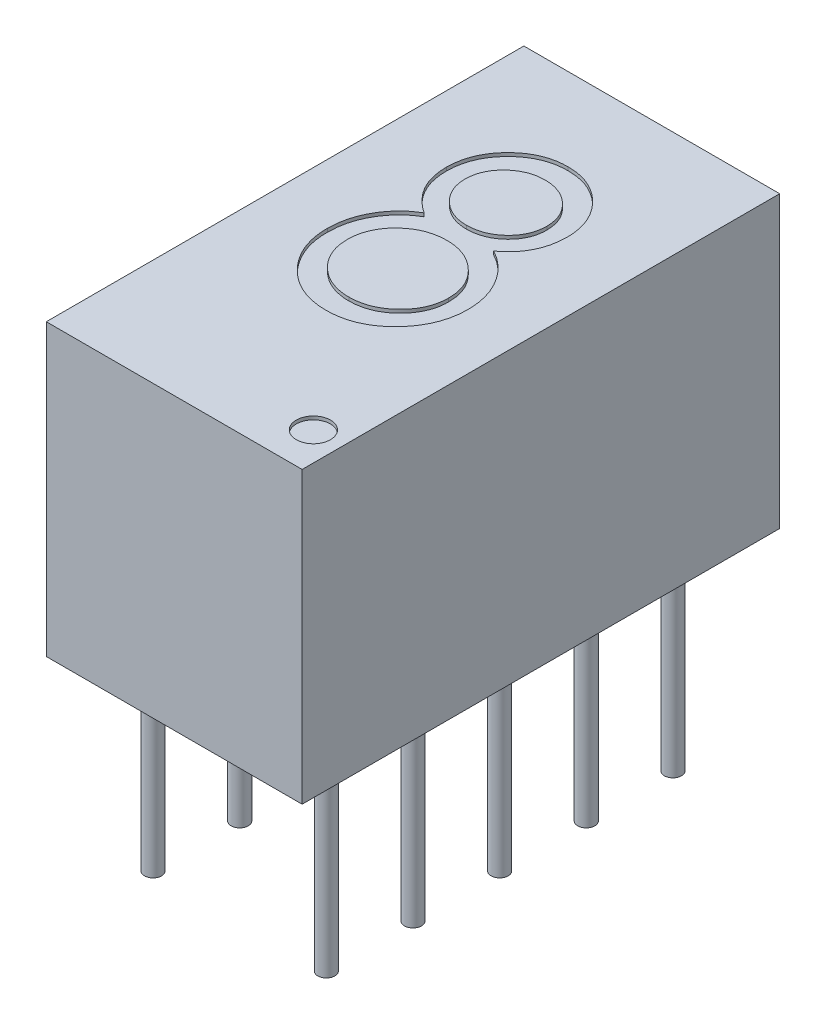
from build123d import *

# Parameters (mm, degrees)
SKETCH_1_W          = 7.5
SKETCH_1_H          = 14
EXTRUDE_1_DEPTH     = 8.5
SKETCH_3_R          = 0.5
CUT_EXTRUDE_1_DEPTH = 0.1
SKETCH_5_R          = 0.25
EXTRUDE_2_DEPTH     = 5.8


with BuildPart() as part:
    # Эскиз1 → Бобышка-Вытянуть1 (new body)
    with BuildSketch(Plane(origin=(0, 0, 0), x_dir=(1, 0, 0), z_dir=(0, 1, 0))):
        Rectangle(SKETCH_1_W, SKETCH_1_H)
    extrude(amount=EXTRUDE_1_DEPTH)

    # Эскиз3 → Вырез-Вытянуть1 (cut)
    with BuildSketch(Plane(origin=(0, 8.5, 0), x_dir=(1, 0, 0), z_dir=(0, 1, 0))):
        with Locations((2.910485727, -5.830946725)):
            Circle(SKETCH_3_R)
        with BuildLine():
            add(Edge.make_bspline(
                [(2.121155078, -0.50483922), (2.119610921, -0.575353546), (2.116575096, -0.713985319), (2.087040205, -0.918279661), (2.038961712, -1.114797376), (1.973166577, -1.304892703), (1.886688616, -1.487323172), (1.78197659, -1.662562127), (1.657407987, -1.830055464), (1.517294235, -1.98880673), (1.361960172, -2.13209451), (1.200545821, -2.261845857), (1.027958933, -2.367621456), (0.84976884, -2.457639593), (0.662148452, -2.524316616), (0.468390235, -2.574879029), (0.266226934, -2.603112848), (0.129148301, -2.607543917), (0.05965128, -2.609790409)],
                knots=[0, 0, 0, 0, 0.000211435, 0.000415684, 0.000617717, 0.000817667, 0.001018055, 0.00122232, 0.001429075, 0.001643446, 0.00185651, 0.002062417, 0.002263626, 0.00246262, 0.00266025, 0.002859739, 0.003062504, 0.003271016, 0.003271016, 0.003271016, 0.003271016], degree=3))
            add(Edge.make_bspline(
                [(0.05965128, -2.609790409), (-0.010888995, -2.608419751), (-0.149643242, -2.605723636), (-0.353155485, -2.573755937), (-0.549123033, -2.526529422), (-0.737102681, -2.458914193), (-0.91663966, -2.371071457), (-1.088089808, -2.264481517), (-1.250652143, -2.137279423), (-1.403333726, -1.993108779), (-1.54323465, -1.836036279), (-1.665173304, -1.668662471), (-1.769604, -1.493894771), (-1.854844828, -1.311174219), (-1.921926234, -1.120612112), (-1.967350345, -0.922026502), (-1.997320876, -0.715997722), (-2.000328331, -0.575860925), (-2.001852517, -0.50483922)],
                knots=[0, 0, 0, 0, 0.000211435, 0.000415898, 0.000616476, 0.000815515, 0.001013848, 0.001215057, 0.00142004, 0.001632011, 0.001844268, 0.002050136, 0.002252347, 0.002454091, 0.002654041, 0.002857182, 0.003064398, 0.00327733, 0.00327733, 0.00327733, 0.00327733], degree=3))
            add(Edge.make_bspline(
                [(-2.001852517, -0.50483922), (-1.998385166, -0.411697298), (-1.991524819, -0.227410851), (-1.937031265, 0.043125235), (-1.849797453, 0.303070227), (-1.728226024, 0.549500305), (-1.5780525, 0.777866462), (-1.401784211, 0.981324501), (-1.202163202, 1.158762714), (-1.052445588, 1.253030314), (-0.977093362, 1.300474789)],
                knots=[0, 0, 0, 0, 0.000279242, 0.000552496, 0.00082444, 0.001099821, 0.001374484, 0.001642127, 0.001905399, 0.002172165, 0.002172165, 0.002172165, 0.002172165], degree=3))
            add(Edge.make_bspline(
                [(-0.977093362, 1.300474789), (-1.043186061, 1.347447939), (-1.172133067, 1.439092663), (-1.341577528, 1.598037796), (-1.487767424, 1.766027966), (-1.605421669, 1.947906942), (-1.698278534, 2.140942889), (-1.762013938, 2.346493715), (-1.802508183, 2.56285791), (-1.807525807, 2.71108272), (-1.810084722, 2.786675201)],
                knots=[0, 0, 0, 0, 0.000243006, 0.000474106, 0.000695108, 0.000909532, 0.001121962, 0.001335658, 0.001553411, 0.001780038, 0.001780038, 0.001780038, 0.001780038], degree=3))
            add(Edge.make_bspline(
                [(-1.810084722, 2.786675201), (-1.808972335, 2.846711132), (-1.806774097, 2.965350854), (-1.779413863, 3.139691302), (-1.740089645, 3.308165859), (-1.681905998, 3.47001905), (-1.608962983, 3.626021501), (-1.518236321, 3.77457472), (-1.412130887, 3.917202284), (-1.290733708, 4.051067508), (-1.158608385, 4.17524507), (-1.017343615, 4.283306119), (-0.869940426, 4.375317638), (-0.71599843, 4.451100091), (-0.555144437, 4.509354088), (-0.388150174, 4.551898183), (-0.214204315, 4.57574584), (-0.096229339, 4.579561458), (-0.036232617, 4.581501909)],
                knots=[0, 0, 0, 0, 0.000179938, 0.000355584, 0.000528188, 0.000698303, 0.000870542, 0.001043976, 0.001219565, 0.001403085, 0.001585409, 0.001762803, 0.001935744, 0.002105932, 0.002276554, 0.002448062, 0.002622013, 0.00280202, 0.00280202, 0.00280202, 0.00280202], degree=3))
            add(Edge.make_bspline(
                [(-0.036232617, 4.581501909), (0.023764104, 4.579561458), (0.141739081, 4.57574584), (0.31568494, 4.551898183), (0.482679202, 4.509354088), (0.643533196, 4.451100091), (0.797475192, 4.375317638), (0.944878381, 4.283306119), (1.086143151, 4.17524507), (1.218268473, 4.051067508), (1.339665653, 3.917202284), (1.445771086, 3.77457472), (1.536497749, 3.626021501), (1.609440763, 3.47001905), (1.66762441, 3.308165859), (1.706948628, 3.139691302), (1.734308862, 2.965350854), (1.736507101, 2.846711132), (1.737619488, 2.786675201)],
                knots=[0, 0, 0, 0, 0.000180007, 0.000353958, 0.000525466, 0.000696088, 0.000866276, 0.001039217, 0.001216611, 0.001398935, 0.001582455, 0.001758044, 0.001931478, 0.002103717, 0.002273832, 0.002446436, 0.002622082, 0.00280202, 0.00280202, 0.00280202, 0.00280202], degree=3))
            add(Edge.make_bspline(
                [(1.737619488, 2.786675201), (1.735184421, 2.712644696), (1.730437273, 2.568322681), (1.697189905, 2.35741071), (1.640449844, 2.159073672), (1.559865791, 1.972574079), (1.457523684, 1.797749946), (1.331889434, 1.634553362), (1.182929281, 1.484074534), (1.069965336, 1.396145165), (1.012497512, 1.351413109)],
                knots=[0, 0, 0, 0, 0.000222055, 0.000432895, 0.000638687, 0.000839344, 0.001040793, 0.00124486, 0.001455678, 0.001673987, 0.001673987, 0.001673987, 0.001673987], degree=3))
            add(Edge.make_bspline(
                [(1.012497512, 1.351413109), (1.094458905, 1.30429308), (1.256819208, 1.210951299), (1.472423159, 1.030313715), (1.663050375, 0.823489416), (1.825135584, 0.590307377), (1.957738762, 0.337664387), (2.053020331, 0.068458504), (2.109517853, -0.214336998), (2.117243932, -0.407204555), (2.121155078, -0.50483922)],
                knots=[0, 0, 0, 0, 0.000283161, 0.000560924, 0.000839784, 0.0011249, 0.001410363, 0.00169325, 0.001978842, 0.002271637, 0.002271637, 0.002271637, 0.002271637], degree=3))
        make_face()
        with BuildLine():
            add(Edge.make_bspline(
                [(1.162316102, 2.759707855), (1.161075378, 2.798720743), (1.15861475, 2.876091878), (1.141765656, 2.989486371), (1.115264605, 3.098804143), (1.075065423, 3.202673942), (1.026675542, 3.303581185), (0.963410683, 3.398216702), (0.89238902, 3.489973671), (0.809199314, 3.574295156), (0.721254942, 3.654189791), (0.624225127, 3.720604954), (0.525307508, 3.780015185), (0.421256004, 3.828950352), (0.31107067, 3.863741424), (0.197666531, 3.891693293), (0.078997247, 3.906225352), (-0.001242231, 3.908932118), (-0.042225361, 3.910314626)],
                knots=[0, 0, 0, 0, 0.000117012, 0.000232061, 0.00034325, 0.00045372, 0.000565614, 0.000678227, 0.000794518, 0.000913187, 0.001033126, 0.001150339, 0.001265192, 0.001379143, 0.00149427, 0.001611282, 0.001729097, 0.001852094, 0.001852094, 0.001852094, 0.001852094], degree=3))
            add(Edge.make_bspline(
                [(-0.042225361, 3.910314626), (-0.082209817, 3.908913676), (-0.160954084, 3.906154686), (-0.277148491, 3.891770235), (-0.388787542, 3.863901364), (-0.49651117, 3.827154112), (-0.599487682, 3.778059387), (-0.699216345, 3.719527302), (-0.794156904, 3.649253124), (-0.883884385, 3.570043388), (-0.965685909, 3.483868338), (-1.037754392, 3.392809573), (-1.098416383, 3.297357827), (-1.148016212, 3.197942274), (-1.187671947, 3.094265098), (-1.213902123, 2.985950239), (-1.231208909, 2.874121395), (-1.233578617, 2.798227166), (-1.234781337, 2.759707855)],
                knots=[0, 0, 0, 0, 0.000120005, 0.000236334, 0.000350432, 0.000464619, 0.000577212, 0.000692066, 0.000811028, 0.000930967, 0.001050719, 0.001167009, 0.001278812, 0.001389364, 0.001499834, 0.001611023, 0.001723107, 0.001838623, 0.001838623, 0.001838623, 0.001838623], degree=3))
            add(Edge.make_bspline(
                [(-1.234781337, 2.759707855), (-1.233578192, 2.721188809), (-1.231207647, 2.645295103), (-1.213906984, 2.533462436), (-1.187653911, 2.425161873), (-1.148083103, 2.321431669), (-1.097975151, 2.221836784), (-1.038257303, 2.12529264), (-0.965636158, 2.034066276), (-0.883830158, 1.94796263), (-0.794642747, 1.868490183), (-0.698717542, 1.800077719), (-0.59955118, 1.741268793), (-0.496494033, 1.69228522), (-0.388792152, 1.655507991), (-0.277147237, 1.627647204), (-0.160954412, 1.613260572), (-0.082209927, 1.610501881), (-0.042225361, 1.609101084)],
                knots=[0, 0, 0, 0, 0.000115516, 0.0002276, 0.000338789, 0.000449259, 0.000559811, 0.000672882, 0.000789172, 0.000908924, 0.001028863, 0.001146944, 0.001261798, 0.001374391, 0.001488578, 0.001602677, 0.001719006, 0.00183901, 0.00183901, 0.00183901, 0.00183901], degree=3))
            add(Edge.make_bspline(
                [(-0.042225361, 1.609101084), (-0.001242806, 1.610484513), (0.078995548, 1.613193083), (0.197672976, 1.62771208), (0.311046814, 1.655712546), (0.421343122, 1.690325638), (0.524757329, 1.739809218), (0.625269058, 1.796731093), (0.720073599, 1.865725278), (0.810428313, 1.943320751), (0.891188265, 2.029510208), (0.964495745, 2.119889496), (1.026137504, 2.215704432), (1.075158792, 2.31667649), (1.11523958, 2.420629063), (1.141772604, 2.529924481), (1.158612953, 2.643325088), (1.161074776, 2.720695388), (1.162316102, 2.759707855)],
                knots=[0, 0, 0, 0, 0.000122997, 0.000240812, 0.000357824, 0.000472951, 0.000586902, 0.000701, 0.000819082, 0.000938034, 0.001057786, 0.001172903, 0.001286775, 0.001398668, 0.001509139, 0.001620328, 0.001735376, 0.001852388, 0.001852388, 0.001852388, 0.001852388], degree=3))
        make_face(mode=Mode.SUBTRACT)
        with BuildLine():
            add(Edge.make_bspline(
                [(1.545851693, -0.500344662), (1.544153958, -0.451855548), (1.540797539, -0.355992638), (1.521912321, -0.214586624), (1.486385978, -0.078878813), (1.439649655, 0.052090021), (1.37423574, 0.175513927), (1.300428005, 0.296419548), (1.209485269, 0.410175017), (1.106669809, 0.516865469), (0.995617169, 0.61556725), (0.876490514, 0.700782673), (0.753627246, 0.774750266), (0.625577327, 0.835782464), (0.49086962, 0.88025421), (0.351479831, 0.91284097), (0.207198333, 0.935376603), (0.109177753, 0.937062151), (0.05965128, 0.937913801)],
                knots=[0, 0, 0, 0, 0.000145517, 0.000287687, 0.000426857, 0.000565736, 0.000703765, 0.000845103, 0.000990172, 0.001139578, 0.001289255, 0.001435203, 0.001578317, 0.001719059, 0.001859768, 0.002002945, 0.002148292, 0.002296734, 0.002296734, 0.002296734, 0.002296734], degree=3))
            add(Edge.make_bspline(
                [(0.05965128, 0.937913801), (0.00912817, 0.937072228), (-0.090381515, 0.935414676), (-0.236208949, 0.913049965), (-0.37648498, 0.880004823), (-0.512228317, 0.835790597), (-0.641453165, 0.775068656), (-0.764514464, 0.701225845), (-0.88238141, 0.615000101), (-0.993331096, 0.517357603), (-1.094824023, 0.410168268), (-1.183781181, 0.295848801), (-1.258672574, 0.176398459), (-1.319613031, 0.051221428), (-1.36732232, -0.078758138), (-1.40254451, -0.214619583), (-1.421511888, -0.355984096), (-1.424857077, -0.451852678), (-1.426549132, -0.500344662)],
                knots=[0, 0, 0, 0, 0.000151435, 0.000298265, 0.000441442, 0.000583572, 0.000725671, 0.000868785, 0.001013521, 0.001163197, 0.001311571, 0.001455716, 0.001597055, 0.001733743, 0.001872623, 0.002011793, 0.002153963, 0.00229948, 0.00229948, 0.00229948, 0.00229948], degree=3))
            add(Edge.make_bspline(
                [(-1.426549132, -0.500344662), (-1.424863171, -0.548839057), (-1.421530029, -0.644712406), (-1.402474508, -0.786042045), (-1.367695307, -0.921577873), (-1.318860571, -1.051086568), (-1.259165188, -1.176823553), (-1.183710808, -1.296504978), (-1.094844924, -1.410869775), (-0.993320444, -1.518032221), (-0.882402459, -1.61573548), (-0.764443776, -1.701752563), (-0.641890452, -1.776247054), (-0.511511058, -1.834173808), (-0.376862879, -1.881268219), (-0.236148072, -1.913571642), (-0.090397457, -1.936147903), (0.009122801, -1.937776337), (0.05965128, -1.938603126)],
                knots=[0, 0, 0, 0, 0.000145517, 0.000287687, 0.000426857, 0.000564331, 0.000702368, 0.000843706, 0.000987852, 0.001136225, 0.001285901, 0.001430637, 0.001573751, 0.001715225, 0.001857836, 0.002001013, 0.002147843, 0.002299278, 0.002299278, 0.002299278, 0.002299278], degree=3))
            add(Edge.make_bspline(
                [(0.05965128, -1.938603126), (0.109181661, -1.937762999), (0.207209976, -1.936100257), (0.351434673, -1.913397141), (0.491193008, -1.881395144), (0.625275202, -1.834568957), (0.753621302, -1.774002086), (0.876930115, -1.700068923), (0.995585152, -1.613120289), (1.10676909, -1.513096766), (1.20905995, -1.404961574), (1.30041366, -1.291133766), (1.374707371, -1.169940744), (1.438910667, -1.045956106), (1.486506033, -0.915895611), (1.521701785, -0.782082876), (1.5409119, -0.642725342), (1.544186525, -0.548340143), (1.545851693, -0.500344662)],
                knots=[0, 0, 0, 0, 0.000148441, 0.000293789, 0.000436965, 0.000578161, 0.000718903, 0.000862017, 0.001008847, 0.001159517, 0.001310008, 0.001455077, 0.001596416, 0.001735779, 0.001873253, 0.002010972, 0.002150175, 0.002294196, 0.002294196, 0.002294196, 0.002294196], degree=3))
        make_face(mode=Mode.SUBTRACT)
    extrude(amount=-CUT_EXTRUDE_1_DEPTH, mode=Mode.SUBTRACT)

    # Эскиз5 → Бобышка-Вытянуть2 (add)
    with BuildSketch(Plane.XZ):
        with Locations((-2.54, -5.08)):
            Circle(SKETCH_5_R)
        with Locations((2.54, -5.08)):
            Circle(SKETCH_5_R)
        with Locations((2.54, -2.54)):
            Circle(SKETCH_5_R)
        with Locations((2.54, 0)):
            Circle(SKETCH_5_R)
        with Locations((2.54, 2.54)):
            Circle(SKETCH_5_R)
        with Locations((2.54, 5.08)):
            Circle(SKETCH_5_R)
        with Locations((-2.54, -2.54)):
            Circle(SKETCH_5_R)
        with Locations((-2.54, 0)):
            Circle(SKETCH_5_R)
        with Locations((-2.54, 2.54)):
            Circle(SKETCH_5_R)
        with Locations((-2.54, 5.08)):
            Circle(SKETCH_5_R)
    extrude(amount=EXTRUDE_2_DEPTH)


solid = part.part
